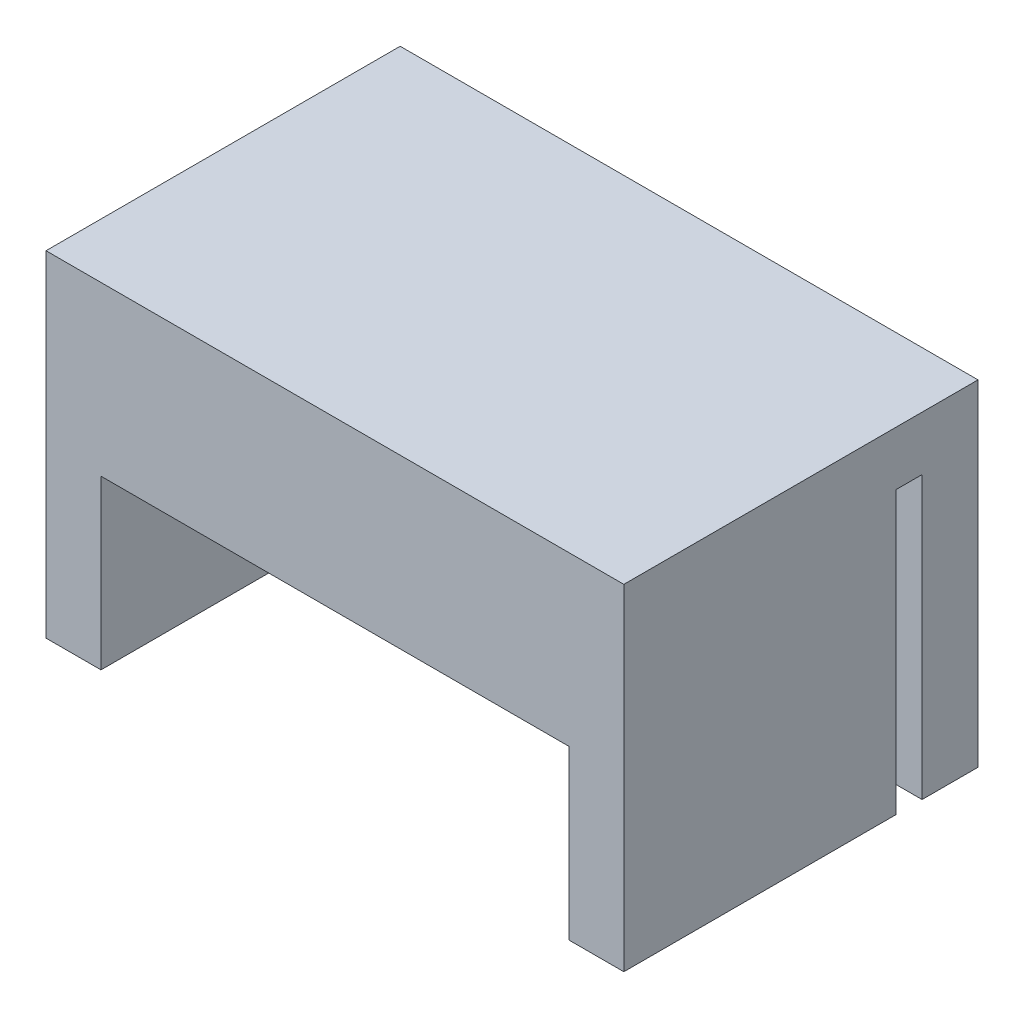
from build123d import *

# Parameters (mm, degrees)
CROQUIS1_W              = 31
CROQUIS1_H              = 18
SALIENTE_EXTRUIR1_DEPTH = 19
CROQUIS3_W              = 25.1
CROQUIS3_H              = 9
CORTAR_EXTRUIR1_DEPTH   = 16
CROQUIS4_W              = 31
CROQUIS4_H              = 1.4
CORTAR_EXTRUIR2_DEPTH   = 15.1
CROQUIS5_R              = 1.5
CORTAR_EXTRUIR3_DEPTH   = 20


with BuildPart() as part:
    # Croquis1 → Saliente-Extruir1 (new body)
    with BuildSketch(Plane.XY):
        Rectangle(CROQUIS1_W, CROQUIS1_H)
    extrude(amount=SALIENTE_EXTRUIR1_DEPTH)

    # Croquis3 → Cortar-Extruir1 (cut)
    with BuildSketch(Plane.XY.offset(19)):
        with Locations((0, -4.5)):
            Rectangle(CROQUIS3_W, CROQUIS3_H)
    extrude(amount=-CORTAR_EXTRUIR1_DEPTH, mode=Mode.SUBTRACT)

    # Croquis4 → Cortar-Extruir2 (cut)
    with BuildSketch(Plane.XZ.offset(9)):
        with Locations((0, 3.7)):
            Rectangle(CROQUIS4_W, CROQUIS4_H)
    extrude(amount=-CORTAR_EXTRUIR2_DEPTH, mode=Mode.SUBTRACT)

    # Croquis5 → Cortar-Extruir3 (cut, through all)
    with BuildSketch(Plane(origin=(0, 0, 0), x_dir=(-1, 0, 0), z_dir=(0, 0, -1))):
        with Locations((-7.5, -4.35)):
            Circle(CROQUIS5_R)
        with Locations((7.5, -4.35)):
            Circle(CROQUIS5_R)
    extrude(amount=-CORTAR_EXTRUIR3_DEPTH, mode=Mode.SUBTRACT)


solid = part.part
